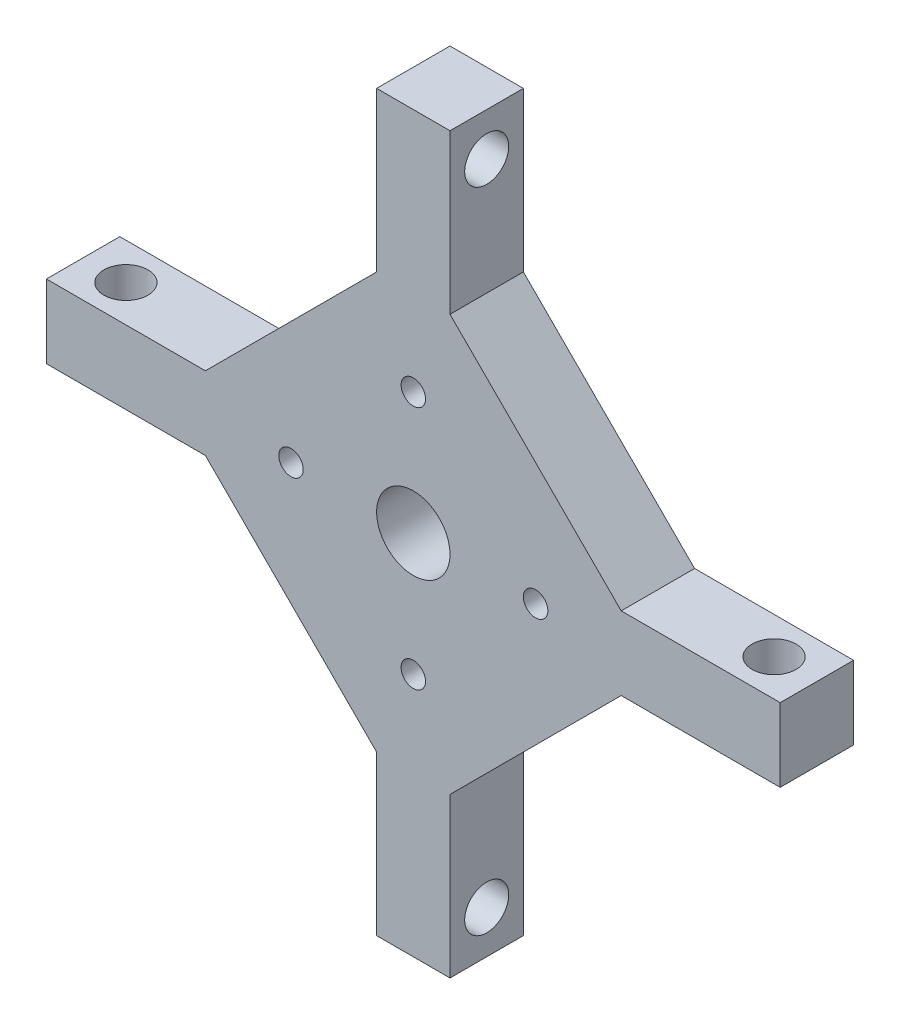
from build123d import *

# Parameters (mm, degrees)
BOSS_EXTRUDE1_DEPTH = 6
SKETCH2_R           = 1.8
CUT_EXTRUDE1_DEPTH  = 6
CIRPATTERN1_COUNT   = 4
SKETCH3_R           = 3
CUT_EXTRUDE2_DEPTH  = 7
SKETCH4_R           = 1
CUT_EXTRUDE3_DEPTH  = 10
CIRPATTERN2_COUNT   = 4


with BuildPart() as part:
    # Sketch1 → Boss-Extrude1 (new body)
    with BuildSketch(Plane.XY):
        Polygon((3, -30), (-3, -30), (-3, -17), (-17, -3), (-30, -3), (-30, 3), (-17, 3), (-3, 17), (-3, 30), (3, 30), (3, 17), (17, 3), (30, 3), (30, -3), (17, -3), (3, -17), align=None)
    extrude(amount=BOSS_EXTRUDE1_DEPTH)

    # Sketch2 → Cut-Extrude1 (cut)
    with BuildSketch(Plane(origin=(3, 0, 0), x_dir=(0, 0, -1), z_dir=(1, 0, 0))):
        with Locations((-3, 26.5)):
            Circle(SKETCH2_R)
    cut_extrude1 = extrude(amount=-CUT_EXTRUDE1_DEPTH, mode=Mode.SUBTRACT)

    # CirPattern1: Cut-Extrude1 ×4 about axis
    cirpattern1_axis = Axis((0, 0, 0), (0, 0, 1))
    for i in range(1, CIRPATTERN1_COUNT):
        add(cut_extrude1.rotate(cirpattern1_axis, i * 360 / CIRPATTERN1_COUNT), mode=Mode.SUBTRACT)

    # Sketch3 → Cut-Extrude2 (cut, through all)
    with BuildSketch(Plane.XY.offset(6)):
        Circle(SKETCH3_R)
    extrude(amount=-CUT_EXTRUDE2_DEPTH, mode=Mode.SUBTRACT)

    # Sketch4 → Cut-Extrude3 (cut)
    with BuildSketch(Plane.XY.offset(6)):
        with Locations((0, 10)):
            Circle(SKETCH4_R)
    cut_extrude3 = extrude(amount=-CUT_EXTRUDE3_DEPTH, mode=Mode.SUBTRACT)

    # CirPattern2: Cut-Extrude3 ×4 about axis
    cirpattern2_axis = Axis((0, 0, 0), (0, 0, 1))
    for i in range(1, CIRPATTERN2_COUNT):
        add(cut_extrude3.rotate(cirpattern2_axis, i * 360 / CIRPATTERN2_COUNT), mode=Mode.SUBTRACT)


solid = part.part
